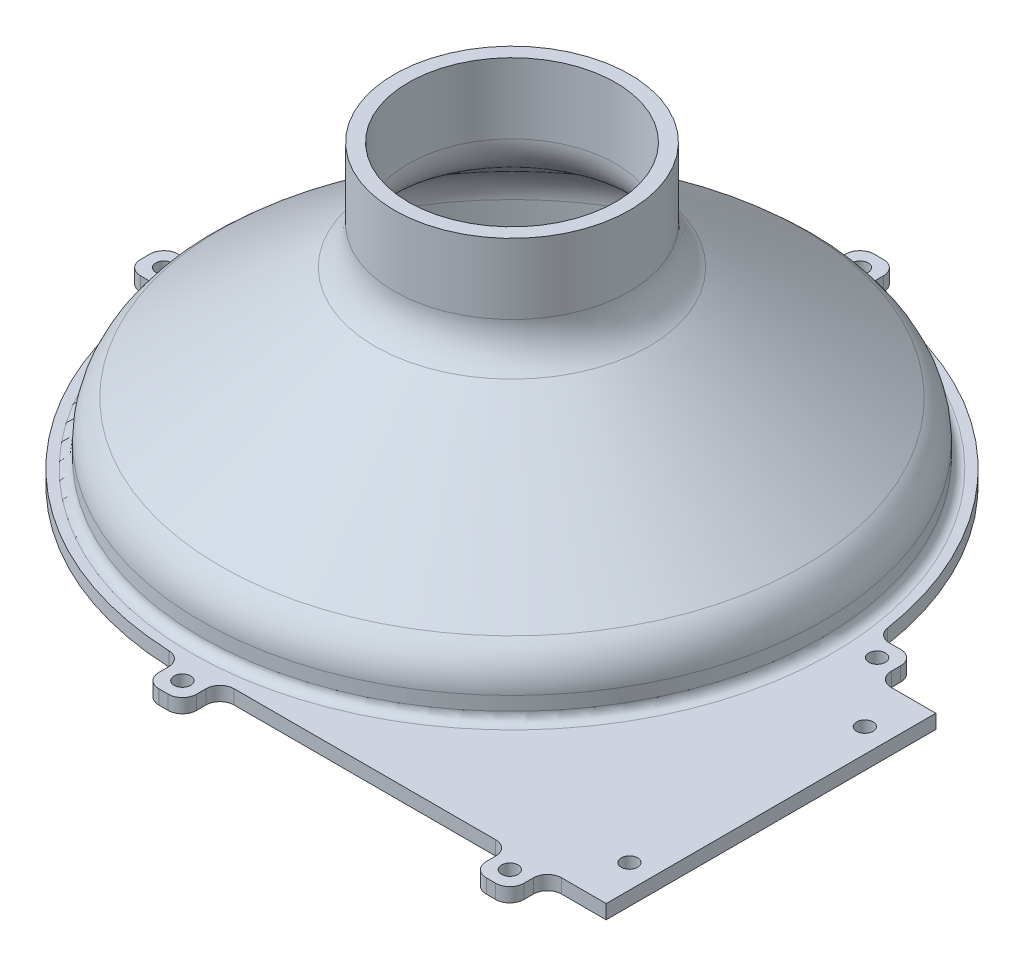
from build123d import *

# Parameters (mm, degrees)
SKETCH2_R           = 63
BOSS_EXTRUDE1_DEPTH = 3
SKETCH3_R           = 66
SKETCH3_R_2         = 63
BOSS_EXTRUDE2_DEPTH = 10
SKETCH7_R           = 25
SKETCH7_R_2         = 22
BOSS_EXTRUDE3_DEPTH = 20
FILLET1_R           = 10
FILLET2_R           = 2
SKETCH8_W           = 8
SKETCH8_H           = 8
SKETCH8_R           = 1.75
BOSS_EXTRUDE4_DEPTH = 3
FILLET3_R           = 3
SKETCH9_R           = 1.75
CUT_EXTRUDE1_DEPTH  = 4.0000001


with BuildPart() as part:
    # Sketch2 → Boss-Extrude1 (new body)
    with BuildSketch(Plane(origin=(0, 0, 0), x_dir=(1, 0, 0), z_dir=(0, 1, 0))):
        with BuildLine():
            Line((0, -70), (90, -70))
            Line((90, -70), (90, 0))
            Line((90, 0), (70, 0))
            ThreePointArc((70, 0), (-49.497474683, 49.497474683), (0, -70))
        make_face()
        Circle(SKETCH2_R, mode=Mode.SUBTRACT)
    extrude(amount=BOSS_EXTRUDE1_DEPTH)

    # Sketch3 → Boss-Extrude2 (add)
    with BuildSketch(Plane(origin=(0, 3, 0), x_dir=(1, 0, 0), z_dir=(0, 1, 0))):
        Circle(SKETCH3_R)
        Circle(SKETCH3_R_2, mode=Mode.SUBTRACT)
    extrude(amount=BOSS_EXTRUDE2_DEPTH)

    # Sketch6 → Revolve1 (revolve)
    with BuildSketch(Plane(origin=(0, 0, 0), x_dir=(0, 0, -1), z_dir=(1, 0, 0))):
        Polygon((-66, 13), (-25, 43), (-22, 43), (-63, 13), align=None)
    revolve(axis=Axis((0, 0, 0), (0, 1, 0)))

    # Sketch7 → Boss-Extrude3 (add)
    with BuildSketch(Plane(origin=(0, 43, 0), x_dir=(1, 0, 0), z_dir=(0, 1, 0))):
        Circle(SKETCH7_R)
        Circle(SKETCH7_R_2, mode=Mode.SUBTRACT)
    extrude(amount=BOSS_EXTRUDE3_DEPTH)

    # Fillet1
    fillet1_edges = [part.edges().sort_by_distance(p)[0] for p in [
        (46.669047558, 13, 46.669047558),
        (-15.556349186, 43, -15.556349186),
        (-44.547727215, 13, -44.547727215),
        (17.67766953, 43, 17.67766953),
    ]]
    fillet(fillet1_edges, radius=FILLET1_R)

    # Fillet2
    fillet2_edges = [part.edges().sort_by_distance(p)[0] for p in [
        (-66, 3, 0),
    ]]
    fillet(fillet2_edges, radius=FILLET2_R)

    # Sketch8 → Boss-Extrude4 (add)
    with BuildSketch(Plane.XZ):
        with Locations((73.541354603, -4)):
            Rectangle(SKETCH8_W, SKETCH8_H)
        with Locations((73.541354603, -4)):
            Circle(SKETCH8_R, mode=Mode.SUBTRACT)
        with Locations((73.541354603, 74)):
            Rectangle(SKETCH8_W, SKETCH8_H)
        with Locations((73.541354603, 74)):
            Circle(SKETCH8_R, mode=Mode.SUBTRACT)
        with Locations((-73.885620839, 0)):
            Rectangle(SKETCH8_W, SKETCH8_H)
        with Locations((-73.885620839, 0)):
            Circle(SKETCH8_R, mode=Mode.SUBTRACT)
        with Locations((0, -73.885620839)):
            Rectangle(SKETCH8_W, SKETCH8_H)
        with Locations((0, -73.885620839)):
            Circle(SKETCH8_R, mode=Mode.SUBTRACT)
        with Locations((4, 74)):
            Rectangle(SKETCH8_W, SKETCH8_H)
        with Locations((4, 74)):
            Circle(SKETCH8_R, mode=Mode.SUBTRACT)
    extrude(amount=-BOSS_EXTRUDE4_DEPTH)

    # Fillet3
    fillet3_edges = [part.edges().sort_by_distance(p)[0] for p in [
        (-4, 1.5, -77.885620839),
        (-4, 1.5, -69.885620839),
        (4, 1.5, -69.885620839),
        (4, 1.5, -77.885620839),
        (0, 1.5, 78),
        (8, 1.5, 78),
        (8, 1.5, 70),
        (77.541354603, 1.5, 0),
        (77.541354603, 1.5, -8),
        (69.541354603, 1.5, -8),
        (77.541354603, 1.5, 78),
        (77.541354603, 1.5, 70),
        (69.541354603, 1.5, 70),
        (69.541354603, 1.5, 78),
        (0, 1.5, 70),
        (-69.885620839, 1.5, 4),
        (-69.885620839, 1.5, -4),
        (-77.885620839, 1.5, -4),
        (-77.885620839, 1.5, 4),
    ]]
    fillet(fillet3_edges, radius=FILLET3_R)

    # Sketch9 → Cut-Extrude1 (cut, through all)
    with BuildSketch(Plane(origin=(0, 3, 0), x_dir=(1, 0, 0), z_dir=(0, 1, 0))):
        with Locations((84.93, -10)):
            Circle(SKETCH9_R)
        with Locations((84.93, -60)):
            Circle(SKETCH9_R)
    extrude(amount=-CUT_EXTRUDE1_DEPTH, mode=Mode.SUBTRACT)


solid = part.part
